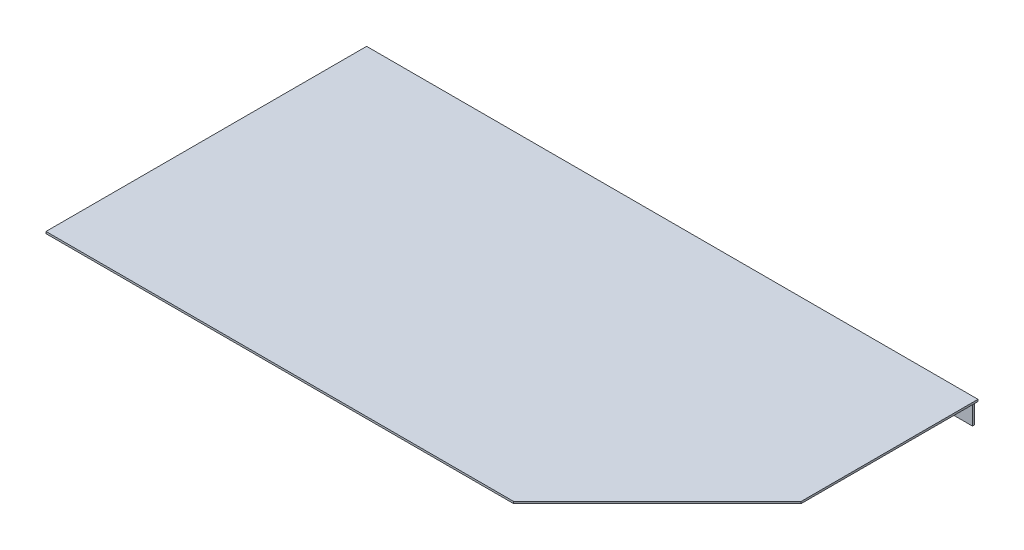
from build123d import *

# Parameters (mm, degrees)
SZKIC2_W                    = 553
SZKIC2_H                    = 1.75
DODANIE_WYCI_GNI_CIE1_DEPTH = 290
WYTNIJ_WYCI_GNI_CIE1_DEPTH  = 10
SZKIC5_W                    = 548
SZKIC5_H                    = 1.75
DODANIE_WYCI_GNI_CIE2_DEPTH = 20


with BuildPart() as part:
    # Szkic2 → Dodanie-wyciągnięcie1 (new body)
    with BuildSketch(Plane.XY):
        with Locations((0, -0.875)):
            Rectangle(SZKIC2_W, SZKIC2_H)
    extrude(amount=DODANIE_WYCI_GNI_CIE1_DEPTH)

    # Szkic3 → Wytnij-wyciągnięcie1 (cut)
    with BuildSketch(Plane(origin=(0, 0, 0), x_dir=(1, 0, 0), z_dir=(0, 1, 0))):
        Polygon((276.5, -290), (146.5, -290), (276.5, -160), align=None)
    extrude(amount=-WYTNIJ_WYCI_GNI_CIE1_DEPTH, mode=Mode.SUBTRACT)

    # Szkic5 → Dodanie-wyciągnięcie2 (add)
    with BuildSketch(Plane.XZ.offset(1.75)):
        with Locations((-0.75, 0.875)):
            Rectangle(SZKIC5_W, SZKIC5_H)
    extrude(amount=DODANIE_WYCI_GNI_CIE2_DEPTH)


solid = part.part
